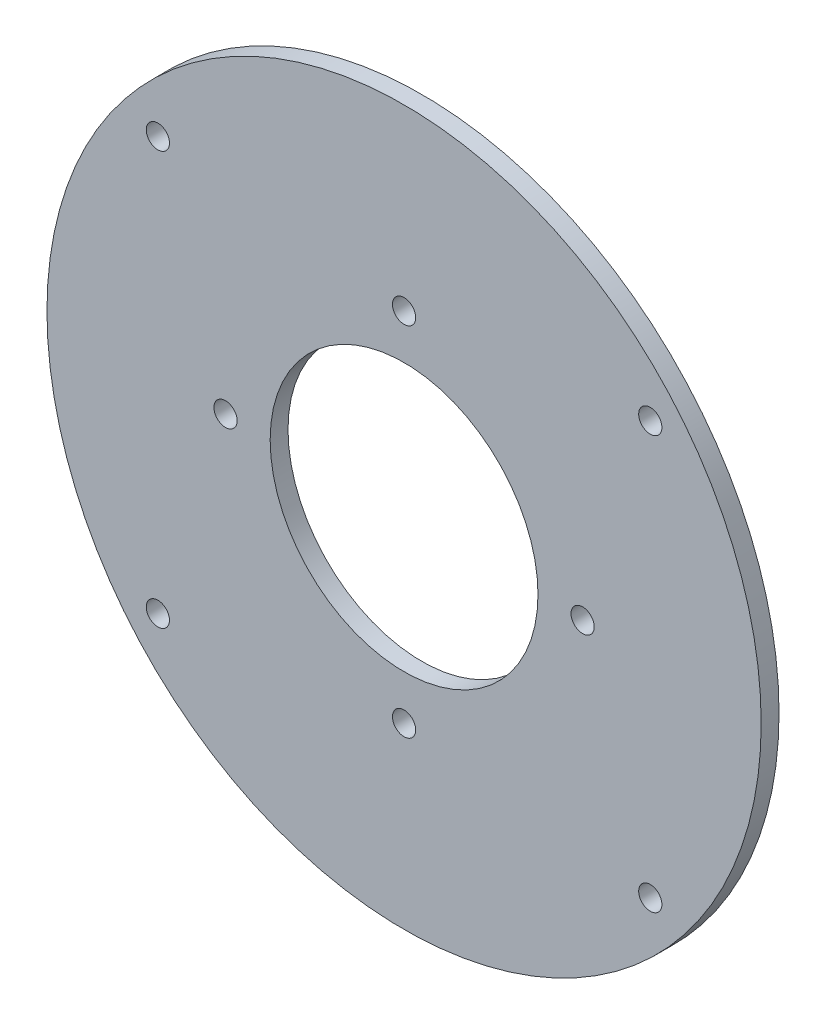
from build123d import *

# Parameters (mm, degrees)
SKETCH1_R           = 80
SKETCH1_R_2         = 2.6
SKETCH1_R_3         = 30
BOSS_EXTRUDE1_DEPTH = 4


with BuildPart() as part:
    # Sketch1 → Boss-Extrude1 (new body)
    with BuildSketch(Plane.XY):
        Circle(SKETCH1_R)
        with Locations((-55.155199905, 46.280707897)):
            Circle(SKETCH1_R_2, mode=Mode.SUBTRACT)
        with Locations((55.155199905, 46.280707897)):
            Circle(SKETCH1_R_2, mode=Mode.SUBTRACT)
        with Locations((55.155199905, -46.280707897)):
            Circle(SKETCH1_R_2, mode=Mode.SUBTRACT)
        with Locations((-55.155199905, -46.280707897)):
            Circle(SKETCH1_R_2, mode=Mode.SUBTRACT)
        Circle(SKETCH1_R_3, mode=Mode.SUBTRACT)
        with Locations((0, -40)):
            Circle(SKETCH1_R_2, mode=Mode.SUBTRACT)
        with Locations((-40, 0)):
            Circle(SKETCH1_R_2, mode=Mode.SUBTRACT)
        with Locations((0, 40)):
            Circle(SKETCH1_R_2, mode=Mode.SUBTRACT)
        with Locations((40, 0)):
            Circle(SKETCH1_R_2, mode=Mode.SUBTRACT)
    extrude(amount=BOSS_EXTRUDE1_DEPTH)


solid = part.part
